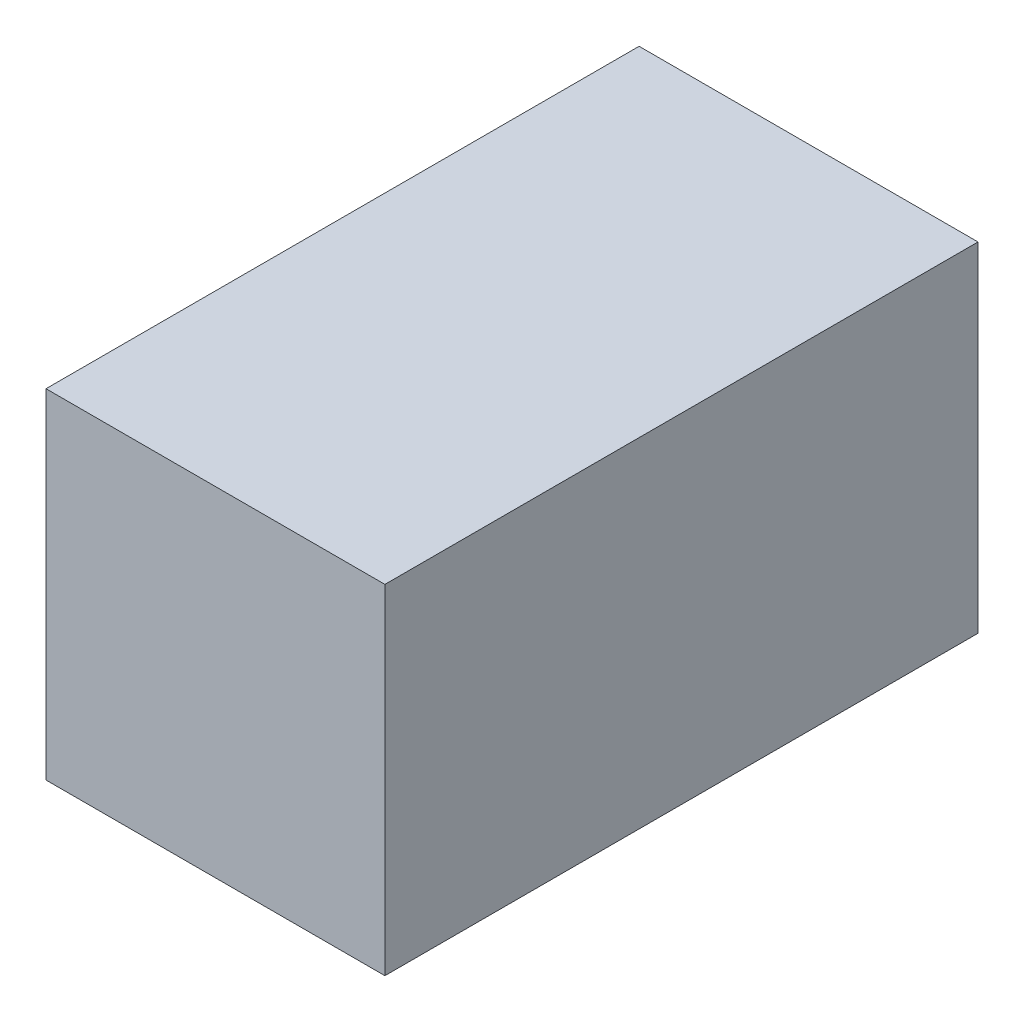
from build123d import *

# Parameters (mm, degrees)
SKETCH1_W           = 50.8
SKETCH1_H           = 50.8
BOSS_EXTRUDE1_DEPTH = 88.9
SKETCH2_W           = 50.8
SKETCH2_H           = 50.8
BOSS_EXTRUDE2_DEPTH = 88.9


with BuildPart() as part:
    # Sketch1 → Boss-Extrude1 (new body)
    with BuildSketch(Plane.XY):
        with Locations((6.35, 0.151190476)):
            Rectangle(SKETCH1_W, SKETCH1_H)
    extrude(amount=BOSS_EXTRUDE1_DEPTH)


with BuildPart() as body_2:
    # Sketch2 → Boss-Extrude2 (new body)
    with BuildSketch(Plane.XY.offset(88.9)):
        with Locations((6.35, 0.151190476)):
            Rectangle(SKETCH2_W, SKETCH2_H)
    extrude(amount=-BOSS_EXTRUDE2_DEPTH)


solid = Compound([part.part, body_2.part])
